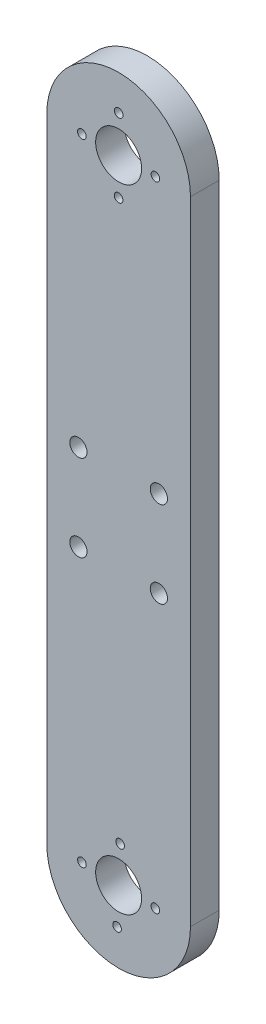
from build123d import *

# Parameters (mm, degrees)
SKETCH2_R           = 4
SKETCH2_R_2         = 1.5
SKETCH2_R_3         = 0.75
BOSS_EXTRUDE1_DEPTH = 5


with BuildPart() as part:
    # Sketch2 → Boss-Extrude1 (new body)
    with BuildSketch(Plane.XY):
        with BuildLine():
            Line((12.5, 0), (12.5, -110))
            ThreePointArc((12.5, -110), (0, -122.5), (-12.5, -110))
            Line((-12.5, -110), (-12.5, 0))
            ThreePointArc((-12.5, 0), (0, 12.5), (12.5, 0))
        make_face()
        Circle(SKETCH2_R, mode=Mode.SUBTRACT)
        with Locations((0, -110)):
            Circle(SKETCH2_R, mode=Mode.SUBTRACT)
        with Locations((7, -47.5)):
            Circle(SKETCH2_R_2, mode=Mode.SUBTRACT)
        with Locations((-7, -47.5)):
            Circle(SKETCH2_R_2, mode=Mode.SUBTRACT)
        with Locations((7, -62.5)):
            Circle(SKETCH2_R_2, mode=Mode.SUBTRACT)
        with Locations((-7, -62.5)):
            Circle(SKETCH2_R_2, mode=Mode.SUBTRACT)
        with Locations((6.390950113, -110.266167545)):
            Circle(SKETCH2_R_3, mode=Mode.SUBTRACT)
        with Locations((-0.266167545, -116.390950113)):
            Circle(SKETCH2_R_3, mode=Mode.SUBTRACT)
        with Locations((-6.390950113, -109.733832455)):
            Circle(SKETCH2_R_3, mode=Mode.SUBTRACT)
        with Locations((0.266167545, -103.609049887)):
            Circle(SKETCH2_R_3, mode=Mode.SUBTRACT)
        with Locations((-6.396483965, 0.009022015)):
            Circle(SKETCH2_R_3, mode=Mode.SUBTRACT)
        with Locations((0.009022015, 6.396483965)):
            Circle(SKETCH2_R_3, mode=Mode.SUBTRACT)
        with Locations((-0.009022015, -6.396483966)):
            Circle(SKETCH2_R_3, mode=Mode.SUBTRACT)
        with Locations((6.396483965, -0.009022016)):
            Circle(SKETCH2_R_3, mode=Mode.SUBTRACT)
    extrude(amount=BOSS_EXTRUDE1_DEPTH)


solid = part.part
